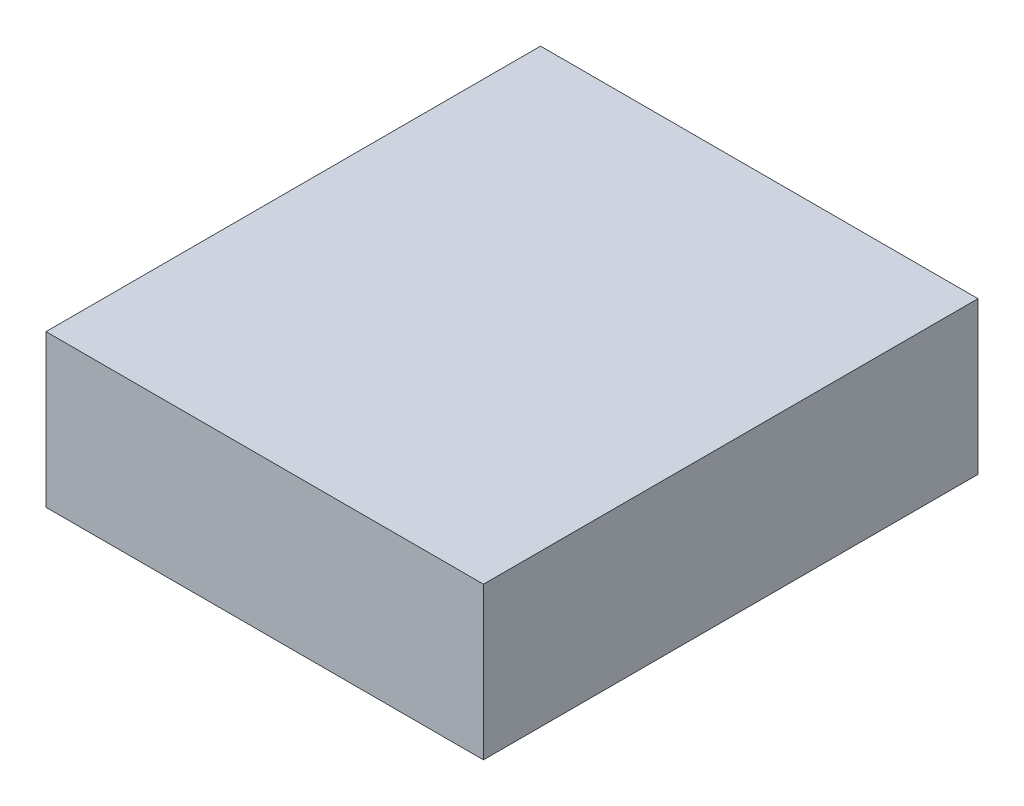
from build123d import *

# Parameters (mm, degrees)
ESQUISSE2_W      = 23
ESQUISSE2_H      = 26
EXTRUSION1_DEPTH = 8


with BuildPart() as part:
    # Esquisse2 → Extrusion1 (new body)
    with BuildSketch(Plane(origin=(0, 0, 0), x_dir=(1, 0, 0), z_dir=(0, 1, 0))):
        with Locations((11.5, 13)):
            Rectangle(ESQUISSE2_W, ESQUISSE2_H)
    extrude(amount=EXTRUSION1_DEPTH)


solid = part.part
